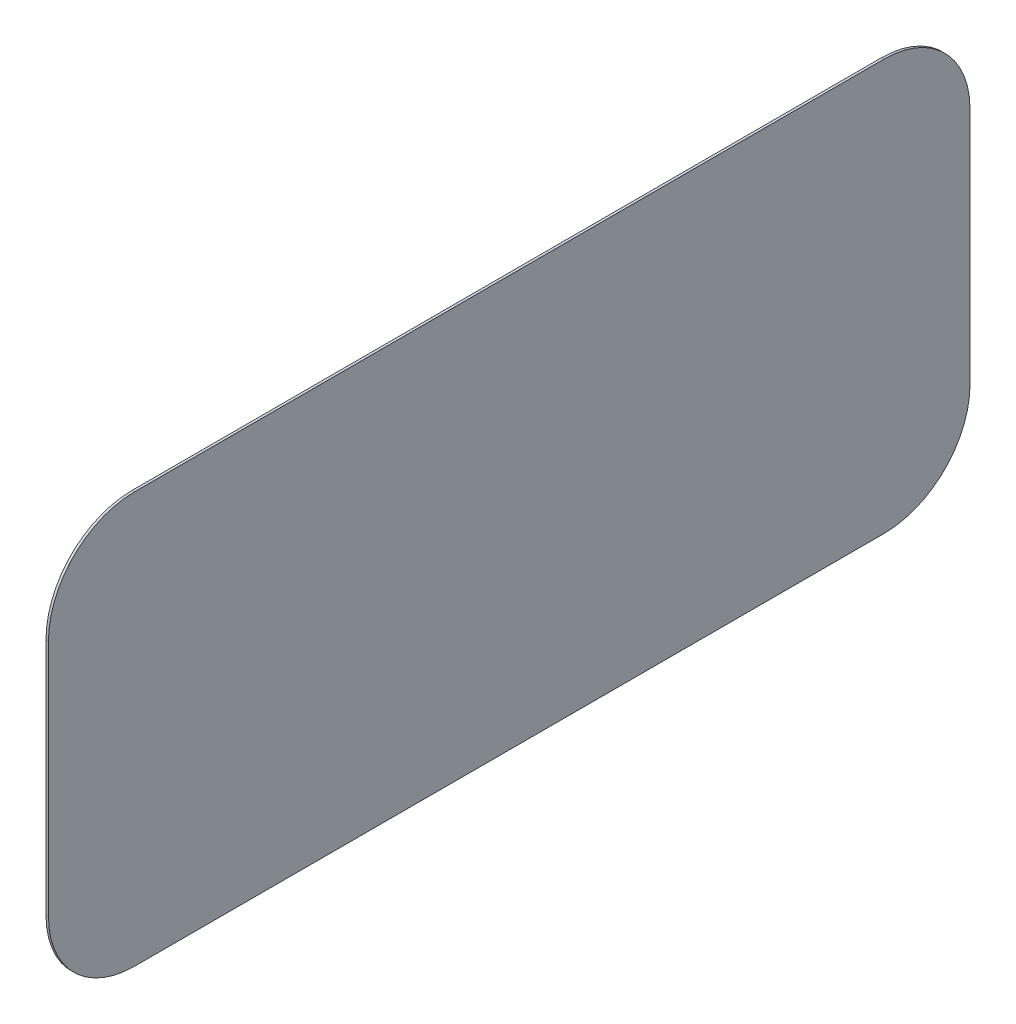
from build123d import *

# Parameters (mm, degrees)
BOSS_EXTRUDE1_DEPTH = 10


with BuildPart() as part:
    # Sketch2 → Boss-Extrude1 (new body)
    with BuildSketch(Plane(origin=(0, 0, 0), x_dir=(0, 0, -1), z_dir=(1, 0, 0))):
        with BuildLine():
            Line((0, 0), (3050, 0))
            ThreePointArc((3050, 0), (3297.487373415, 102.512626585), (3400, 350))
            Line((3400, 350), (3400, 1322))
            ThreePointArc((3400, 1322), (3297.487373415, 1569.487373415), (3050, 1672))
            Line((3050, 1672), (0, 1672))
            ThreePointArc((0, 1672), (-247.487373415, 1569.487373415), (-350, 1322))
            Line((-350, 1322), (-350, 350))
            ThreePointArc((-350, 350), (-247.487373415, 102.512626585), (0, 0))
        make_face()
    extrude(amount=-BOSS_EXTRUDE1_DEPTH)


solid = part.part
